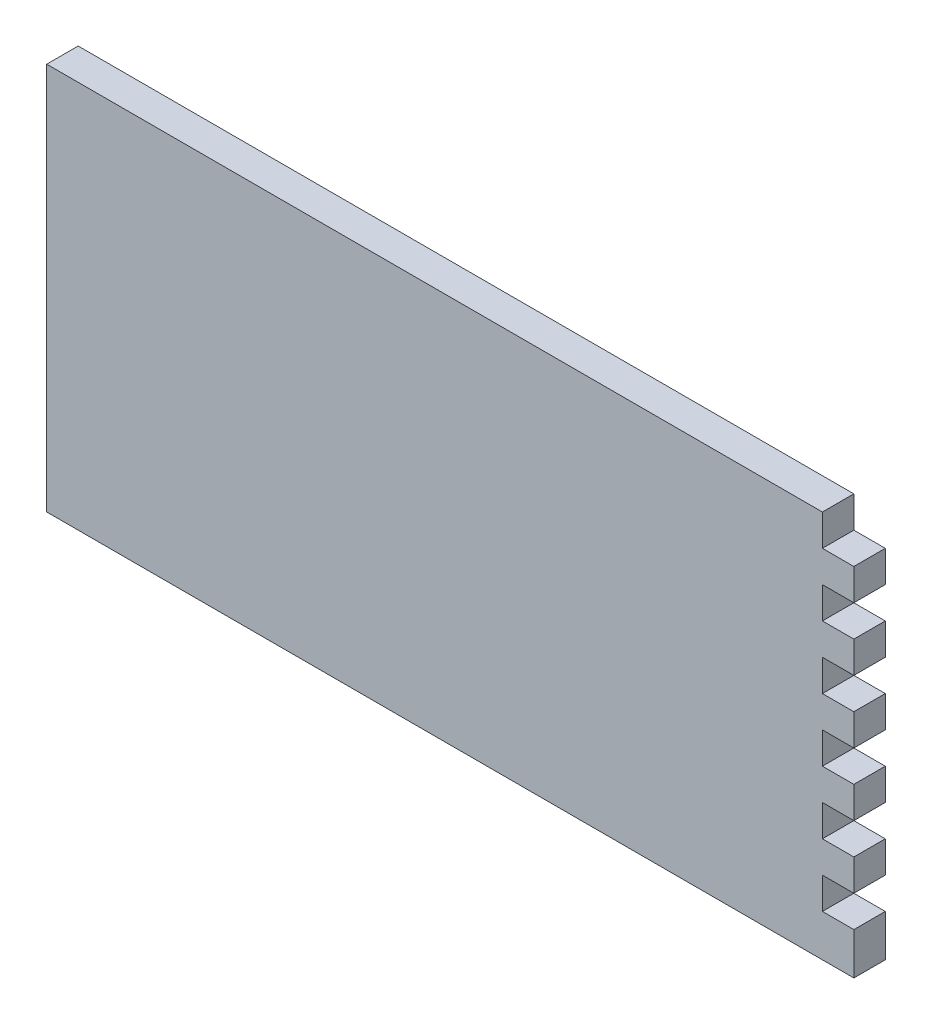
from build123d import *

# Parameters (mm, degrees)
SKETCH1_W           = 192.5
SKETCH1_H           = 7.5
BOSS_EXTRUDE1_DEPTH = 92.5
SKETCH4_W           = 7.5
SKETCH4_H           = 7.5
CUT_EXTRUDE1_DEPTH  = 92.5


with BuildPart() as part:
    # Sketch1 → Boss-Extrude1 (new body)
    with BuildSketch(Plane(origin=(0, 0, 0), x_dir=(1, 0, 0), z_dir=(0, 1, 0))):
        with Locations((-96.25, 3.75)):
            Rectangle(SKETCH1_W, SKETCH1_H)
    extrude(amount=BOSS_EXTRUDE1_DEPTH)

    # Sketch4 → Cut-Extrude1 (cut)
    with BuildSketch(Plane.XY):
        with Locations((-3.75, 88.75)):
            Rectangle(SKETCH4_W, SKETCH4_H)
        with Locations((-3.75, 73.75)):
            Rectangle(SKETCH4_W, SKETCH4_H)
        with Locations((-3.75, 58.75)):
            Rectangle(SKETCH4_W, SKETCH4_H)
        with Locations((-3.75, 43.75)):
            Rectangle(SKETCH4_W, SKETCH4_H)
        with Locations((-3.75, 28.75)):
            Rectangle(SKETCH4_W, SKETCH4_H)
        with Locations((-3.75, 13.75)):
            Rectangle(SKETCH4_W, SKETCH4_H)
    extrude(amount=-CUT_EXTRUDE1_DEPTH, mode=Mode.SUBTRACT)


solid = part.part
